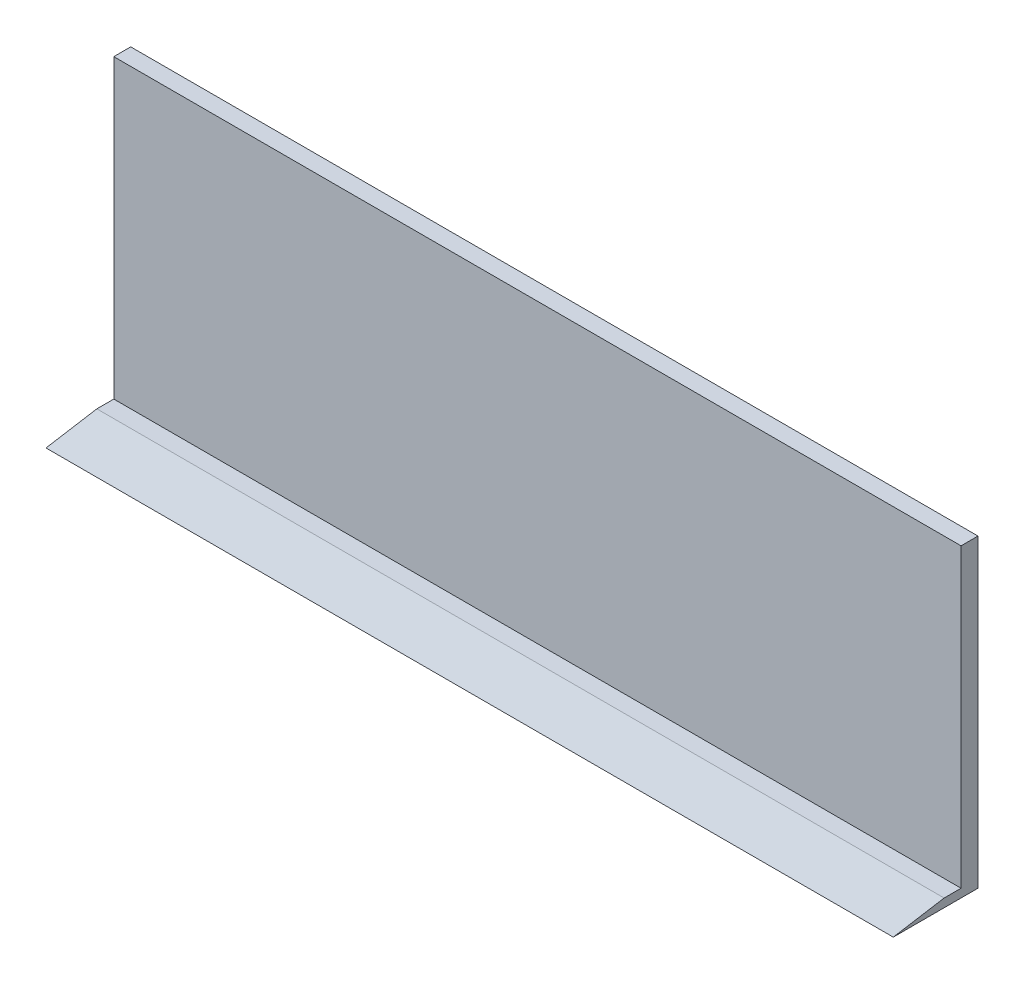
from build123d import *

# Parameters (mm, degrees)
ESQUISSE1_W        = 250
ESQUISSE1_H        = 90
BOSS_EXTRU_1_DEPTH = 5
BOSS_EXTRU_2_DEPTH = 250


with BuildPart() as part:
    # Esquisse1 → Boss.-Extru.1 (new body)
    with BuildSketch(Plane.XY):
        with Locations((-125, 45)):
            Rectangle(ESQUISSE1_W, ESQUISSE1_H)
    extrude(amount=BOSS_EXTRU_1_DEPTH)

    # Esquisse2 → Boss.-Extru.2 (add)
    with BuildSketch(Plane(origin=(0, 0, 0), x_dir=(0, 0, -1), z_dir=(1, 0, 0))):
        Polygon((-5, 0), (-25, 0), (-10, 2.5), (-5, 2.5), align=None)
    extrude(amount=-BOSS_EXTRU_2_DEPTH)


solid = part.part
